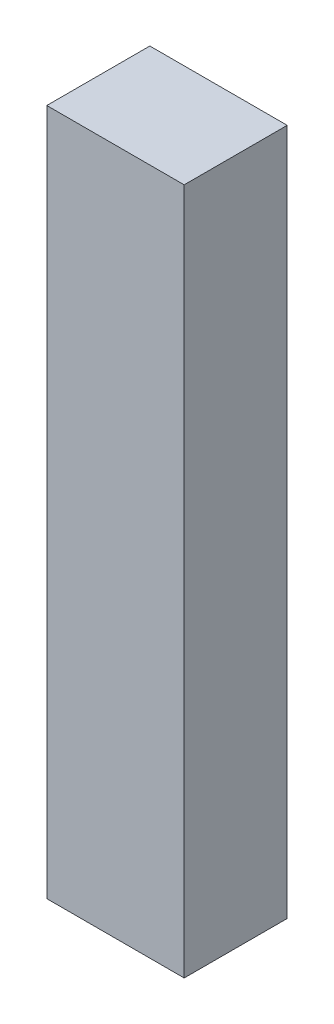
from build123d import *

# Parameters (mm, degrees)
SKETCH_1_W      = 400
SKETCH_1_H      = 300
EXTRUDE_1_DEPTH = 2000


with BuildPart() as part:
    # 草圖1 → 填料-伸長1 (new body)
    with BuildSketch(Plane(origin=(0, 0, 0), x_dir=(1, 0, 0), z_dir=(0, 1, 0))):
        Rectangle(SKETCH_1_W, SKETCH_1_H)
    extrude(amount=EXTRUDE_1_DEPTH)


solid = part.part
